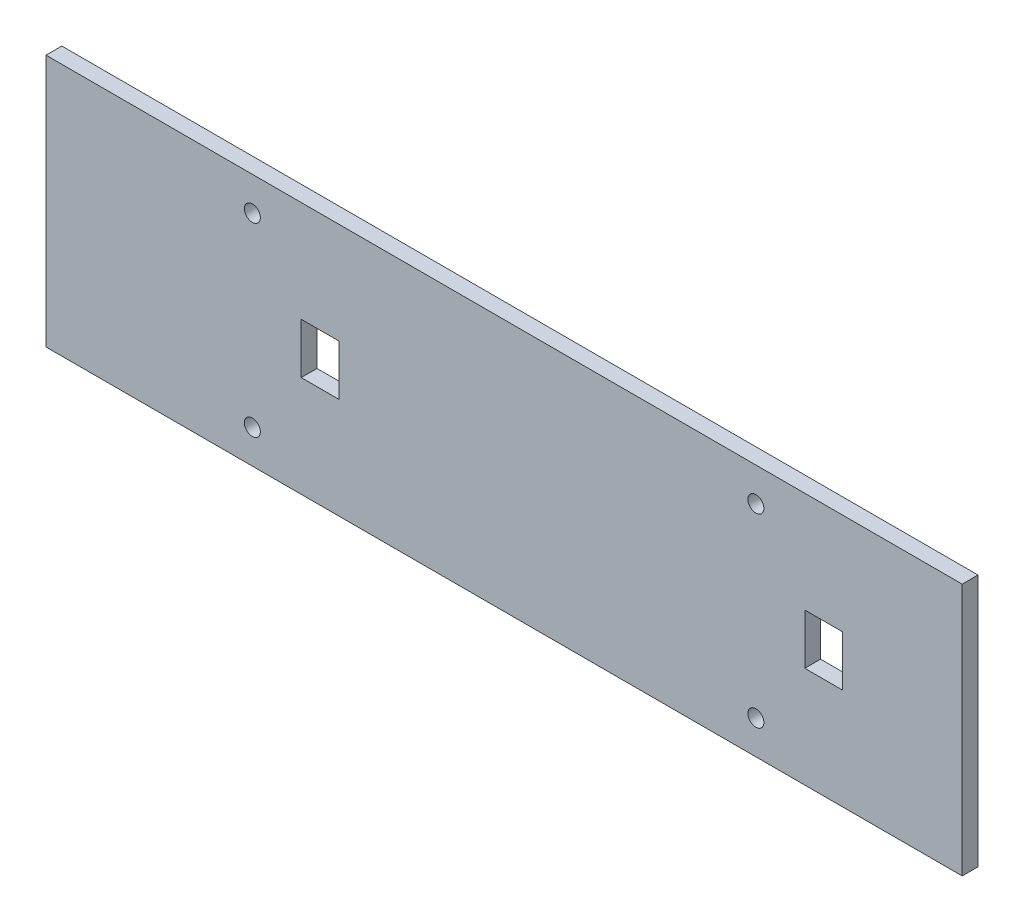
from build123d import *

# Parameters (mm, degrees)
SKETCH2_W           = 184.15
SKETCH2_H           = 50.8
BOSS_EXTRUDE1_DEPTH = 1.5875
SKETCH3_R           = 1.61
SKETCH3_W           = 7.62
SKETCH3_H           = 10.15
CUT_EXTRUDE1_DEPTH  = 5.08


with BuildPart() as part:
    # Sketch2 → Boss-Extrude1 (new body, symmetric)
    with BuildSketch(Plane.XY):
        Rectangle(SKETCH2_W, SKETCH2_H)
    extrude(amount=BOSS_EXTRUDE1_DEPTH, both=True)

    # Sketch3 → Cut-Extrude1 (cut)
    with BuildSketch(Plane.XY.offset(1.5875)):
        with Locations((-50.605000009, 18.64)):
            Circle(SKETCH3_R)
        with Locations((-50.605000009, -18.64)):
            Circle(SKETCH3_R)
        with Locations((50.605000009, 18.64)):
            Circle(SKETCH3_R)
        with Locations((50.605000009, -18.64)):
            Circle(SKETCH3_R)
        with Locations((-36.970000018, 0)):
            Rectangle(SKETCH3_W, SKETCH3_H)
        with Locations((64.24, 0)):
            Rectangle(SKETCH3_W, SKETCH3_H)
    extrude(amount=-CUT_EXTRUDE1_DEPTH, mode=Mode.SUBTRACT)


solid = part.part
